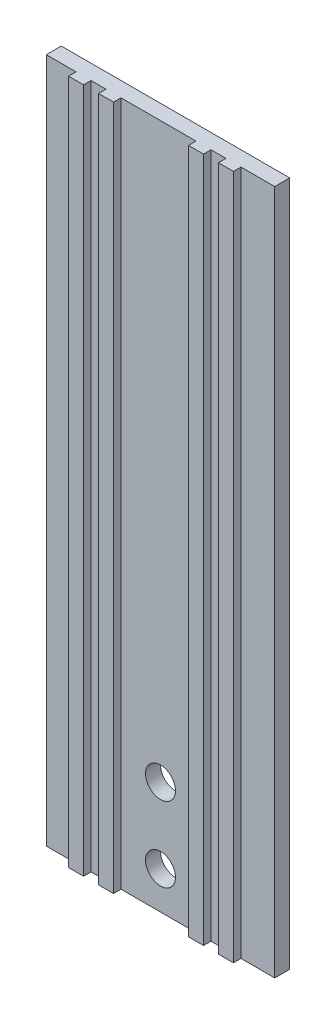
from build123d import *

# Parameters (mm, degrees)
SKETCH1_W           = 152.4
SKETCH1_H           = 457.2
SKETCH1_R           = 10
BOSS_EXTRUDE1_DEPTH = 10
SKETCH2_W           = 10
SKETCH2_H           = 457.2
EXTRUDE_THIN1_DEPTH = 5


with BuildPart() as part:
    # Sketch1 → Boss-Extrude1 (new body)
    with BuildSketch(Plane.XY):
        Rectangle(SKETCH1_W, SKETCH1_H)
        with Locations((0, -203.6)):
            Circle(SKETCH1_R, mode=Mode.SUBTRACT)
        with Locations((0, -153.6)):
            Circle(SKETCH1_R, mode=Mode.SUBTRACT)
    extrude(amount=BOSS_EXTRUDE1_DEPTH)

    # Sketch2 → Extrude-Thin1 (add)
    with BuildSketch(Plane.XY.offset(10)):
        with Locations((28.665766577, 0)):
            Rectangle(SKETCH2_W, SKETCH2_H)
        with Locations((48.665766577, 0)):
            Rectangle(SKETCH2_W, SKETCH2_H)
        with Locations((-31.334233423, 0)):
            Rectangle(SKETCH2_W, SKETCH2_H)
        with Locations((-51.334233423, 0)):
            Rectangle(SKETCH2_W, SKETCH2_H)
    extrude(amount=EXTRUDE_THIN1_DEPTH)


solid = part.part
